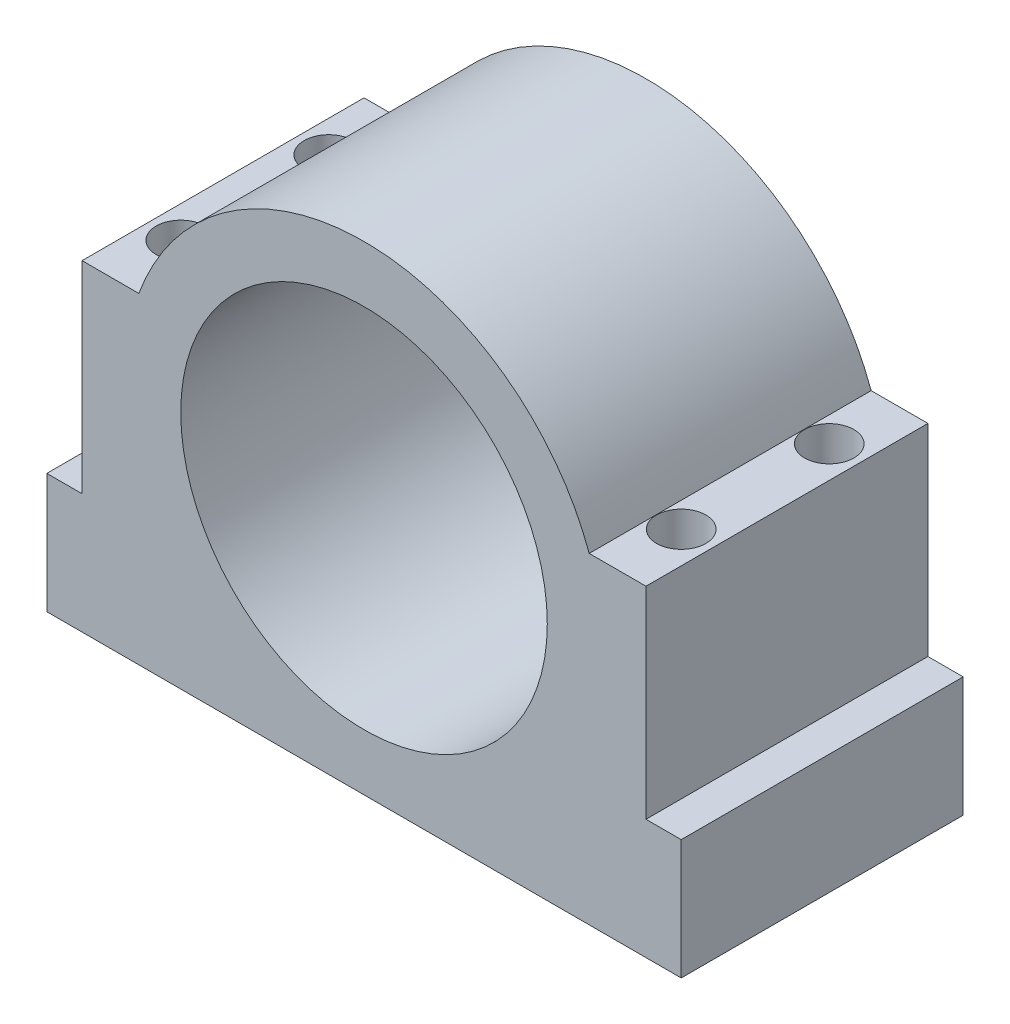
from build123d import *

# Parameters (mm, degrees)
SKETCH1_R           = 26
BOSS_EXTRUDE1_DEPTH = 40
SKETCH2_R           = 3.5
CUT_EXTRUDE1_DEPTH  = 100


with BuildPart() as part:
    # Sketch1 → Boss-Extrude1 (new body)
    with BuildSketch(Plane.XY):
        with BuildLine():
            Line((40, 17), (45, 17))
            Line((45, 17), (45, 0))
            Line((45, 0), (-45, 0))
            Line((-45, 0), (-45, 17))
            Line((-45, 17), (-40, 17))
            Line((-40, 17), (-40, 45.637906937))
            Line((-40, 45.637906937), (-31.946191042, 45.637906937))
            ThreePointArc((-31.946191042, 45.637906937), (0, 68), (31.946191042, 45.637906937))
            Line((31.946191042, 45.637906937), (40, 45.637906937))
            Line((40, 45.637906937), (40, 17))
        make_face()
        with Locations((0, 34)):
            Circle(SKETCH1_R, mode=Mode.SUBTRACT)
    extrude(amount=BOSS_EXTRUDE1_DEPTH)

    # Sketch2 → Cut-Extrude1 (cut)
    with BuildSketch(Plane.XZ):
        with Locations((-35.5, 30.5)):
            Circle(SKETCH2_R)
        with Locations((-35.5, 9.5)):
            Circle(SKETCH2_R)
        with Locations((35.5, 30.5)):
            Circle(SKETCH2_R)
        with Locations((35.5, 9.5)):
            Circle(SKETCH2_R)
    extrude(amount=-CUT_EXTRUDE1_DEPTH, mode=Mode.SUBTRACT)


solid = part.part
